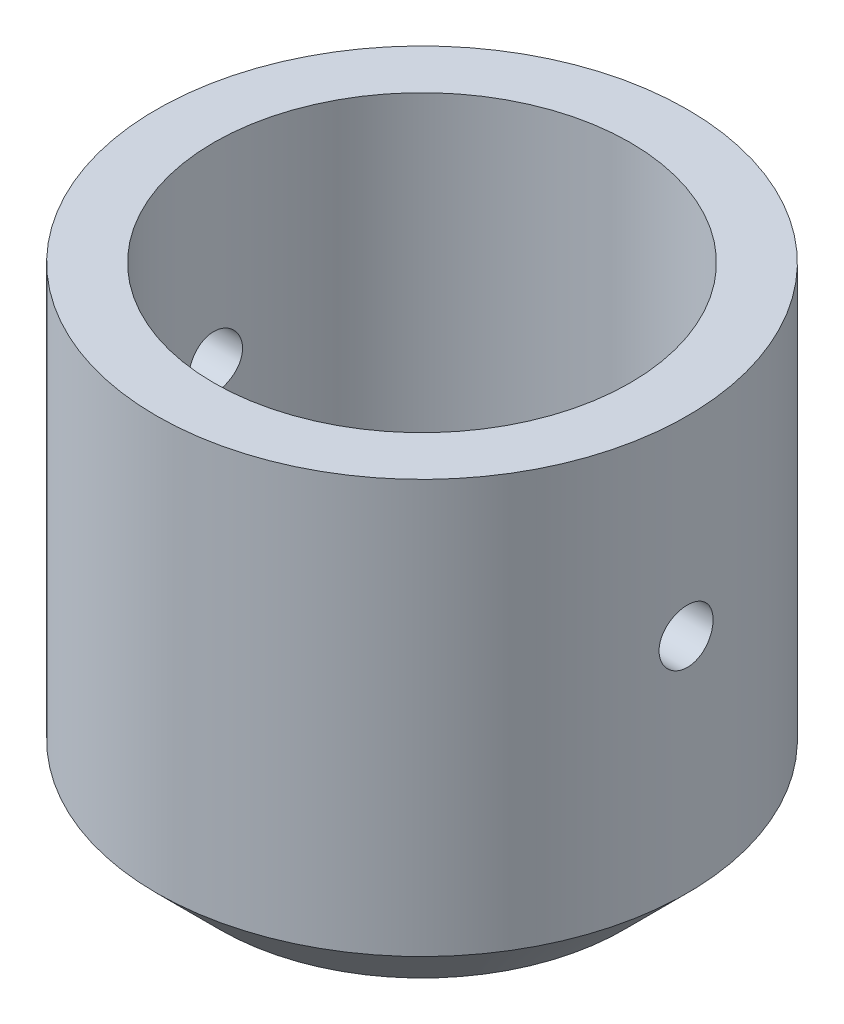
from build123d import *

# Parameters (mm, degrees)
SKETCH1_R               = 8.35
BOSS_EXTRUDE1_DEPTH     = 15
SKETCH2_R               = 6.55
CUT_EXTRUDE1_DEPTH      = 12
SKETCH3_R               = 0.85
CUT_EXTRUDE2_DEPTH      = 9.35
CUT_EXTRUDE2_DEPTH_BACK = 9.35
SKETCH4_R               = 4.15
CUT_EXTRUDE3_DEPTH      = 16.0000001
CHAMFER1_SIZE           = 2


with BuildPart() as part:
    # Sketch1 → Boss-Extrude1 (new body)
    with BuildSketch(Plane(origin=(0, 0, 0), x_dir=(1, 0, 0), z_dir=(0, 1, 0))):
        Circle(SKETCH1_R)
    extrude(amount=BOSS_EXTRUDE1_DEPTH)

    # Sketch2 → Cut-Extrude1 (cut)
    with BuildSketch(Plane(origin=(0, 15, 0), x_dir=(1, 0, 0), z_dir=(0, 1, 0))):
        Circle(SKETCH2_R)
    extrude(amount=-CUT_EXTRUDE1_DEPTH, mode=Mode.SUBTRACT)

    # Sketch3 → Cut-Extrude2 (cut, two sides)
    with BuildSketch(Plane(origin=(0, 0, 0), x_dir=(0, 0, -1), z_dir=(1, 0, 0))) as cut_extrude2_sk:
        with Locations((0, 9)):
            Circle(SKETCH3_R)
    extrude(amount=CUT_EXTRUDE2_DEPTH, mode=Mode.SUBTRACT)
    extrude(cut_extrude2_sk.sketch, amount=-CUT_EXTRUDE2_DEPTH_BACK, mode=Mode.SUBTRACT)

    # Sketch4 → Cut-Extrude3 (cut, through all)
    with BuildSketch(Plane.XZ):
        Circle(SKETCH4_R)
    extrude(amount=-CUT_EXTRUDE3_DEPTH, mode=Mode.SUBTRACT)

    # Chamfer1
    chamfer1_edges = [part.edges().sort_by_distance(p)[0] for p in [
        (-8.35, 0, 0),
    ]]
    chamfer(chamfer1_edges, length=CHAMFER1_SIZE)


solid = part.part
